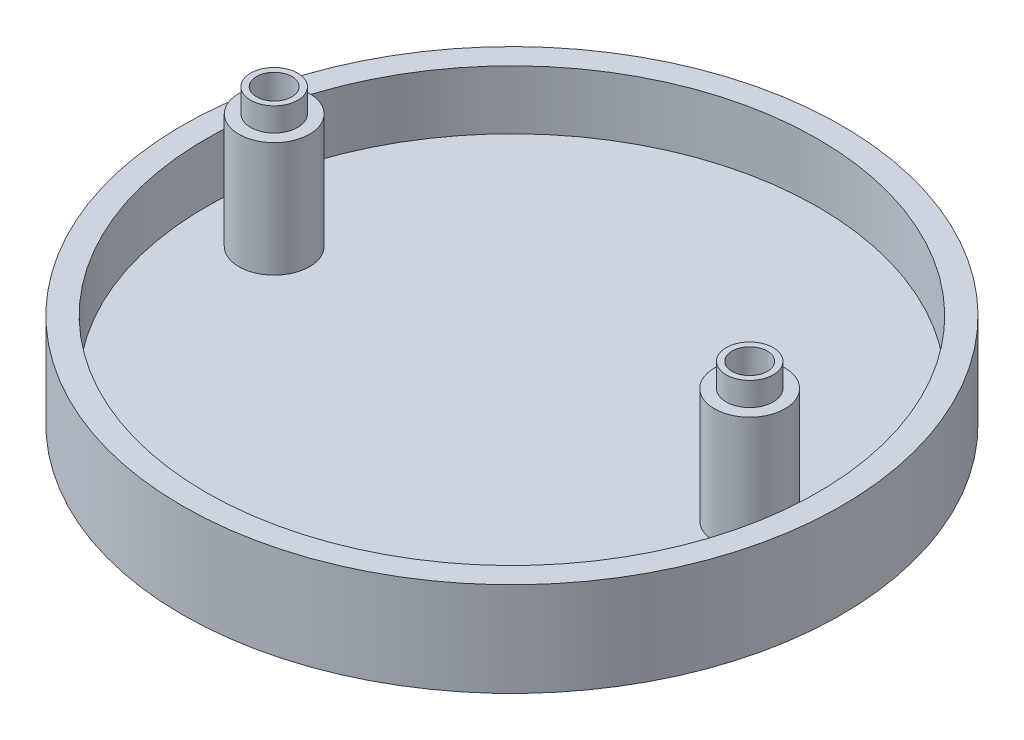
from build123d import *

# Parameters (mm, degrees)
SKETCH1_R                  = 28
SKETCH1_R_2                = 26
BOSS_EXTRUDE1_DEPTH        = 8
SKETCH3_R                  = 24
BOSS_EXTRUDE2_DEPTH        = 3
SKETCH5_R                  = 2
BOSS_EXTRUDE3_DEPTH        = 11.75
BOSS_EXTRUDE3_DEPTH_BACK   = 2.5
BOSS_EXTRUDE3_2_DEPTH      = 11.75
BOSS_EXTRUDE3_2_DEPTH_BACK = 2.5
SKETCH10_R                 = 28
BOSS_EXTRUDE4_DEPTH        = 3
SKETCH16_R                 = 3
BOSS_EXTRUDE5_DEPTH        = 9.75
SKETCH20_R                 = 1.5
CUT_EXTRUDE2_DEPTH         = 30
SKETCH21_R                 = 2.5
CUT_EXTRUDE3_DEPTH         = 1


with BuildPart() as part:
    # Sketch1 → Boss-Extrude1 (new body)
    with BuildSketch(Plane(origin=(0, 0, 0), x_dir=(1, 0, 0), z_dir=(0, 1, 0))):
        Circle(SKETCH1_R)
        Circle(SKETCH1_R_2, mode=Mode.SUBTRACT)
    extrude(amount=BOSS_EXTRUDE1_DEPTH)



with BuildPart() as body_2:
    # Sketch3 → Boss-Extrude2 (new body)
    with BuildSketch(Plane(origin=(0, 0, 0), x_dir=(1, 0, 0), z_dir=(0, 1, 0))):
        Circle(SKETCH3_R)
    extrude(amount=BOSS_EXTRUDE2_DEPTH)


with BuildPart() as body_3:
    # Sketch5 → Boss-Extrude3 (new body, two sides)
    with BuildSketch(Plane(origin=(0, 3, 0), x_dir=(1, 0, 0), z_dir=(0, 1, 0))) as boss_extrude3_sk:
        with Locations((-20.2, 0)):
            Circle(SKETCH5_R)
    extrude(amount=BOSS_EXTRUDE3_DEPTH)
    extrude(boss_extrude3_sk.sketch, amount=-BOSS_EXTRUDE3_DEPTH_BACK)


with BuildPart() as body_4:
    # Sketch5 → Boss-Extrude3 2 (new body, two sides)
    with BuildSketch(Plane(origin=(0, 3, 0), x_dir=(1, 0, 0), z_dir=(0, 1, 0))) as boss_extrude3_2_sk:
        with Locations((20.2, 0)):
            Circle(SKETCH5_R)
    extrude(amount=BOSS_EXTRUDE3_2_DEPTH)
    extrude(boss_extrude3_2_sk.sketch, amount=-BOSS_EXTRUDE3_2_DEPTH_BACK)


with BuildPart() as part_1:
    add(part.part)

    add(body_2.part)  # Boss-Extrude4 merges body 2

    add(body_3.part)  # Boss-Extrude4 merges body 3

    add(body_4.part)  # Boss-Extrude4 merges body 4
    # Sketch10 → Boss-Extrude4 (add)
    with BuildSketch(Plane(origin=(0, 0, 0), x_dir=(-1, 0, 0), z_dir=(0, -1, 0))):
        Circle(SKETCH10_R)
    extrude(amount=-BOSS_EXTRUDE4_DEPTH)

    # Sketch16 → Boss-Extrude5 (add)
    with BuildSketch(Plane(origin=(0, 3, 0), x_dir=(1, 0, 0), z_dir=(0, 1, 0))):
        with Locations((20.2, 0)):
            Circle(SKETCH16_R)
        with Locations((-20.2, 0)):
            Circle(SKETCH16_R)
    extrude(amount=BOSS_EXTRUDE5_DEPTH)

    # Sketch20 → Cut-Extrude2 (cut)
    with BuildSketch(Plane(origin=(0, 14.75, 0), x_dir=(1, 0, 0), z_dir=(0, 1, 0))):
        with Locations((20.2, 0)):
            Circle(SKETCH20_R)
        with Locations((-20.2, 0)):
            Circle(SKETCH20_R)
    extrude(amount=-CUT_EXTRUDE2_DEPTH, mode=Mode.SUBTRACT)

    # Sketch21 → Cut-Extrude3 (cut)
    with BuildSketch(Plane.XZ):
        with Locations((20.2, 0)):
            Circle(SKETCH21_R)
        with Locations((-20.2, 0)):
            Circle(SKETCH21_R)
    extrude(amount=-CUT_EXTRUDE3_DEPTH, mode=Mode.SUBTRACT)


solid = part_1.part
